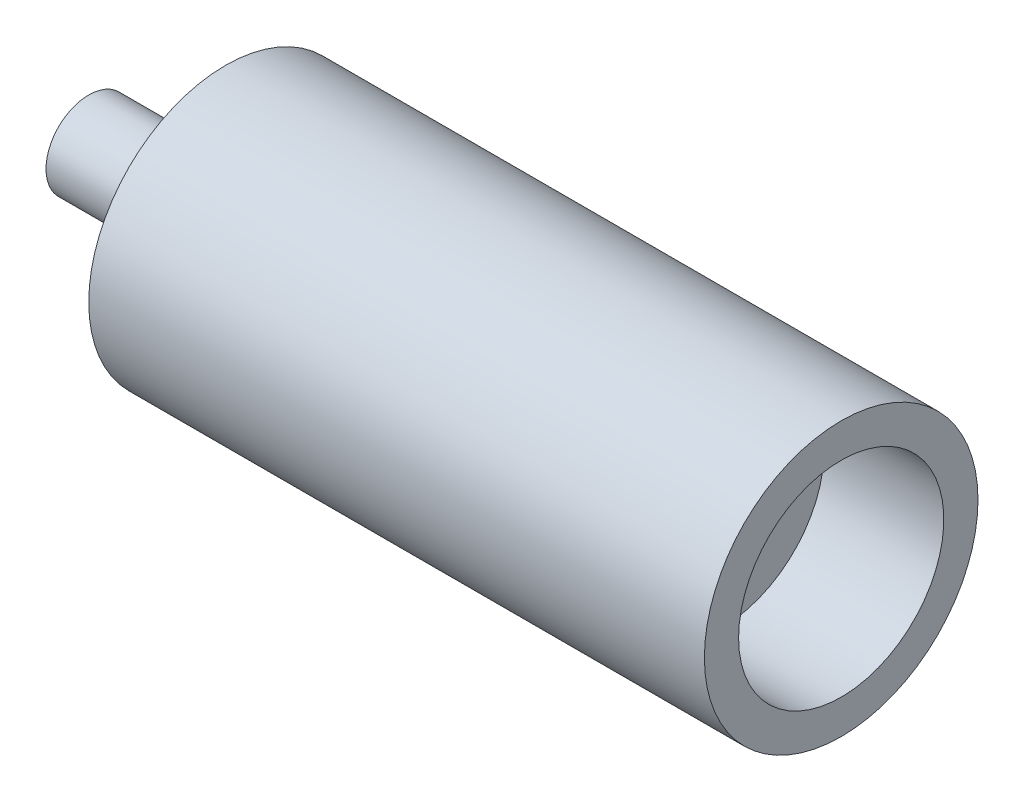
from build123d import *


with BuildPart() as part:
    # Sketch1 → Revolve1 (revolve)
    with BuildSketch(Plane.XY):
        Polygon((0, 6.35), (0, 12.5), (30, 12.5), (30, 20), (33, 25), (35, 25), (35, 32.5), (40, 32.5), (40, 40), (220, 40), (220, 30), (185, 30), (185, 5), (50, 5), (50, 6.35), align=None)
    revolve(axis=Axis((1.424970928, 0, 0), (1, 0, 0)))


solid = part.part
